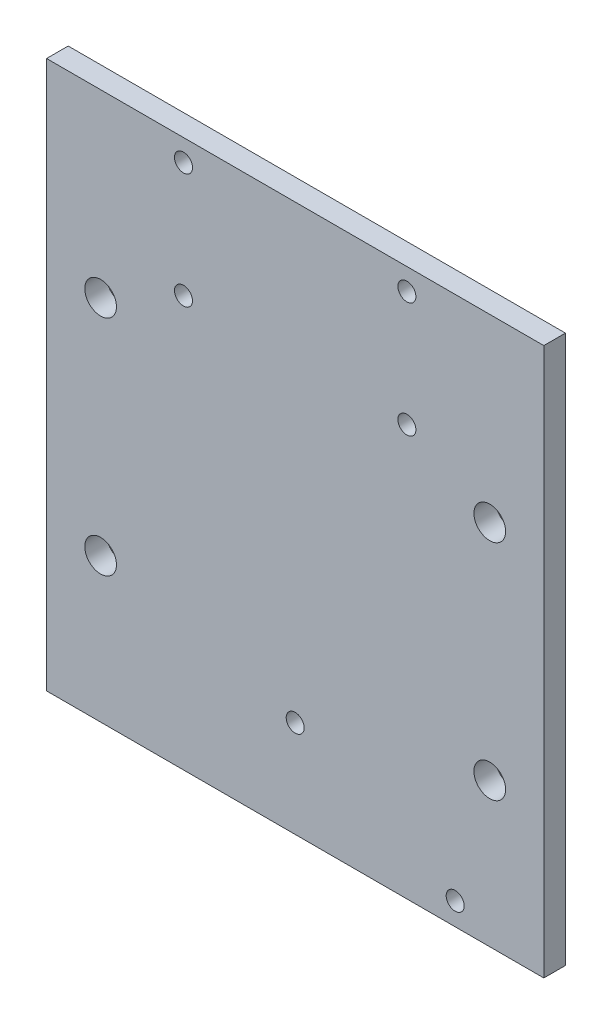
from build123d import *

# Parameters (mm, degrees)
SKETCH_1_W          = 7.5
SKETCH_1_H          = 9.347826087
SKETCH_1_H_2        = 10
EXTRUDE_1_DEPTH     = 3
SKETCH_2_R          = 2.2
CUT_EXTRUDE_1_DEPTH = 4
M3X0_5_1_D          = 2.5
M3X0_5_1_DEPTH      = 8.5
M3X0_5_1_TIP        = 0.751075774
SKETCH_6_W          = 69
SKETCH_6_H          = 3
CUT_EXTRUDE_2_DEPTH = 20
SKETCH_7_W          = 69
SKETCH_7_H          = 3
EXTRUDE_2_DEPTH     = 10
M3X0_5_2_D          = 2.5
M3X0_5_2_DEPTH      = 8.5
M3X0_5_2_TIP        = 0.751075774


with BuildPart() as part:
    # ｽｹｯﾁ1 → ﾎﾞｽ - 押し出し1 (new body)
    with BuildSketch(Plane.XY):
        Polygon((27, 43), (-27, 43), (-27, 33.652173913), (-34.5, 33.652173913), (-34.5, -33), (-27, -33), (-27, -43), (27, -43), (27, -33), (34.5, -33), (34.5, 33.652173913), (27, 33.652173913), align=None)
        with Locations((-30.75, 38.326086956)):
            Rectangle(SKETCH_1_W, SKETCH_1_H)
        with Locations((30.75, 38.326086956)):
            Rectangle(SKETCH_1_W, SKETCH_1_H)
        with Locations((30.75, -38)):
            Rectangle(SKETCH_1_W, SKETCH_1_H_2)
        with Locations((-30.75, -38)):
            Rectangle(SKETCH_1_W, SKETCH_1_H_2)
    extrude(amount=EXTRUDE_1_DEPTH)

    # ｽｹｯﾁ2 → ｶｯﾄ - 押し出し1 (cut, through all)
    with BuildSketch(Plane.XY.offset(3)):
        with Locations((-27, 18)):
            Circle(SKETCH_2_R)
        with Locations((27, 18)):
            Circle(SKETCH_2_R)
        with Locations((27, -13)):
            Circle(SKETCH_2_R)
        with Locations((-27, -13)):
            Circle(SKETCH_2_R)
    extrude(amount=-CUT_EXTRUDE_1_DEPTH, mode=Mode.SUBTRACT)

    # M3x0.5 ねじ穴1
    with Locations(Plane(origin=(-15.5, 24, 3), x_dir=(1, 0, 0), z_dir=(0, 0, 1))):
        with Locations((0, 0), (31, 0), (0, 16), (31, 16)):
            Hole(M3X0_5_1_D / 2, depth=M3X0_5_1_DEPTH)
            with Locations((0, 0, -(M3X0_5_1_DEPTH + M3X0_5_1_TIP / 2))):  # 118° drill point
                Cone(0, M3X0_5_1_D / 2, M3X0_5_1_TIP, mode=Mode.SUBTRACT)

    # ｽｹｯﾁ6 → ｶｯﾄ - 押し出し2 (cut)
    with BuildSketch(Plane(origin=(0, -43, 0), x_dir=(-1, 0, 0), z_dir=(0, -1, 0))):
        with Locations((0, -1.5)):
            Rectangle(SKETCH_6_W, SKETCH_6_H)
    extrude(amount=-CUT_EXTRUDE_2_DEPTH, mode=Mode.SUBTRACT)

    # ｽｹｯﾁ7 → ﾎﾞｽ - 押し出し2 (add)
    with BuildSketch(Plane(origin=(0, -23, 0), x_dir=(-1, 0, 0), z_dir=(0, -1, 0))):
        with Locations((0, -1.5)):
            Rectangle(SKETCH_7_W, SKETCH_7_H)
    extrude(amount=EXTRUDE_2_DEPTH)

    # M3x0.5 ねじ穴2
    with Locations(Plane(origin=(0, -19.574626956, 3), x_dir=(1, 0, 0), z_dir=(0, 0, 1))):
        with Locations((0, 0), (22.2, -10.3)):
            Hole(M3X0_5_2_D / 2, depth=M3X0_5_2_DEPTH)
            with Locations((0, 0, -(M3X0_5_2_DEPTH + M3X0_5_2_TIP / 2))):  # 118° drill point
                Cone(0, M3X0_5_2_D / 2, M3X0_5_2_TIP, mode=Mode.SUBTRACT)


solid = part.part
